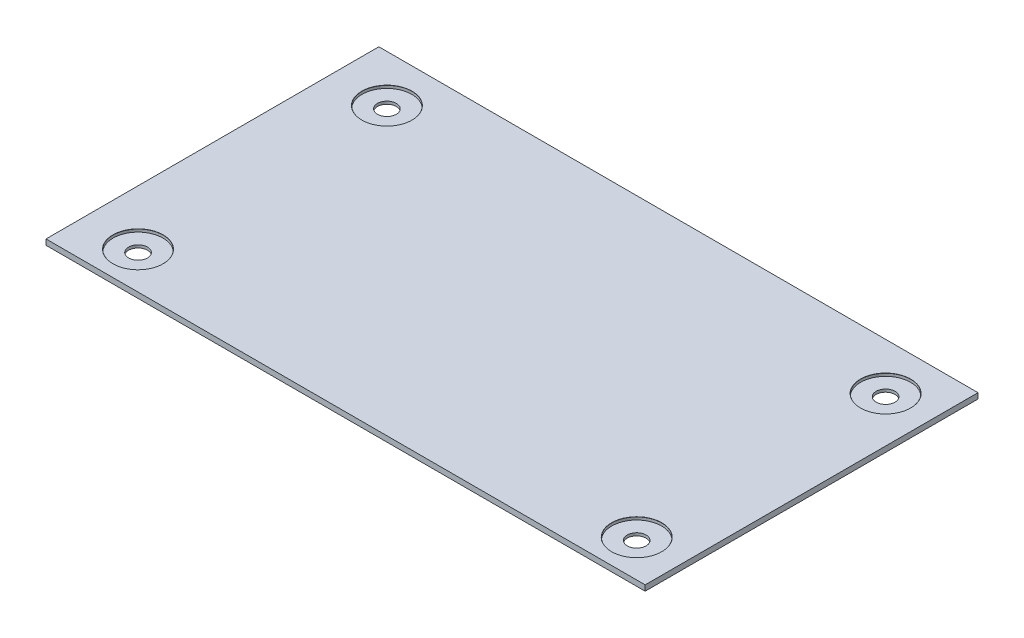
from build123d import *

# Parameters (mm, degrees)
SKETCH_2_W                  = 108
SKETCH_2_H                  = 60
EXTRUDE_1_DEPTH             = 1
HOLE_WIZARD_M3_1_AT_2_COUNT = 2
HOLE_WIZARD_M3_1_AT_2_PITCH = 89.888096236
HOLE_WIZARD_M3_1_AT_3_COUNT = 2
HOLE_WIZARD_M3_1_AT_3_PITCH = 44.863801861
HOLE_WIZARD_M3_1_AT_4_COUNT = 2
HOLE_WIZARD_M3_1_AT_4_PITCH = 100.462085198


with BuildPart() as part:
    # 草图2 → 凸台-拉伸1 (new body)
    with BuildSketch(Plane(origin=(0, 0, 0), x_dir=(1, 0, 0), z_dir=(0, 1, 0))):
        Rectangle(SKETCH_2_W, SKETCH_2_H)
    extrude(amount=EXTRUDE_1_DEPTH)

    # 草图4 → M3 六角头螺栓的柱形沉头孔1 (revolve, cut)
    with BuildSketch(Plane(origin=(-44.084962343, 1, -21.539091549), x_dir=(0, 0, 1), z_dir=(1, 0, 0))):
        Polygon((0, 0), (0, 1), (1.7, 1), (1.7, 0.5), (4.5, 0.5), (4.5, 0.025), (4.525, 0), align=None)
    hole_wizard_m3_1 = revolve(axis=Axis((-44.084962343, 7.35, -21.539091549), (0, -1, 0)), mode=Mode.SUBTRACT)

    # M3 六角头螺栓的柱形沉头孔1 at 2: M3 六角头螺栓的柱形沉头孔1 ×2
    with Locations(*[(i * HOLE_WIZARD_M3_1_AT_2_PITCH, 0, 0) for i in range(1, HOLE_WIZARD_M3_1_AT_2_COUNT)]):
        add(hole_wizard_m3_1, mode=Mode.SUBTRACT)

    # M3 六角头螺栓的柱形沉头孔1 at 3: M3 六角头螺栓的柱形沉头孔1 ×2
    with Locations(*[(0, 0, i * HOLE_WIZARD_M3_1_AT_3_PITCH) for i in range(1, HOLE_WIZARD_M3_1_AT_3_COUNT)]):
        add(hole_wizard_m3_1, mode=Mode.SUBTRACT)

    # M3 六角头螺栓的柱形沉头孔1 at 4: M3 六角头螺栓的柱形沉头孔1 ×2
    with Locations(*[Vector(0.894746471, 0, 0.446574464) * (i * HOLE_WIZARD_M3_1_AT_4_PITCH) for i in range(1, HOLE_WIZARD_M3_1_AT_4_COUNT)]):
        add(hole_wizard_m3_1, mode=Mode.SUBTRACT)


solid = part.part
